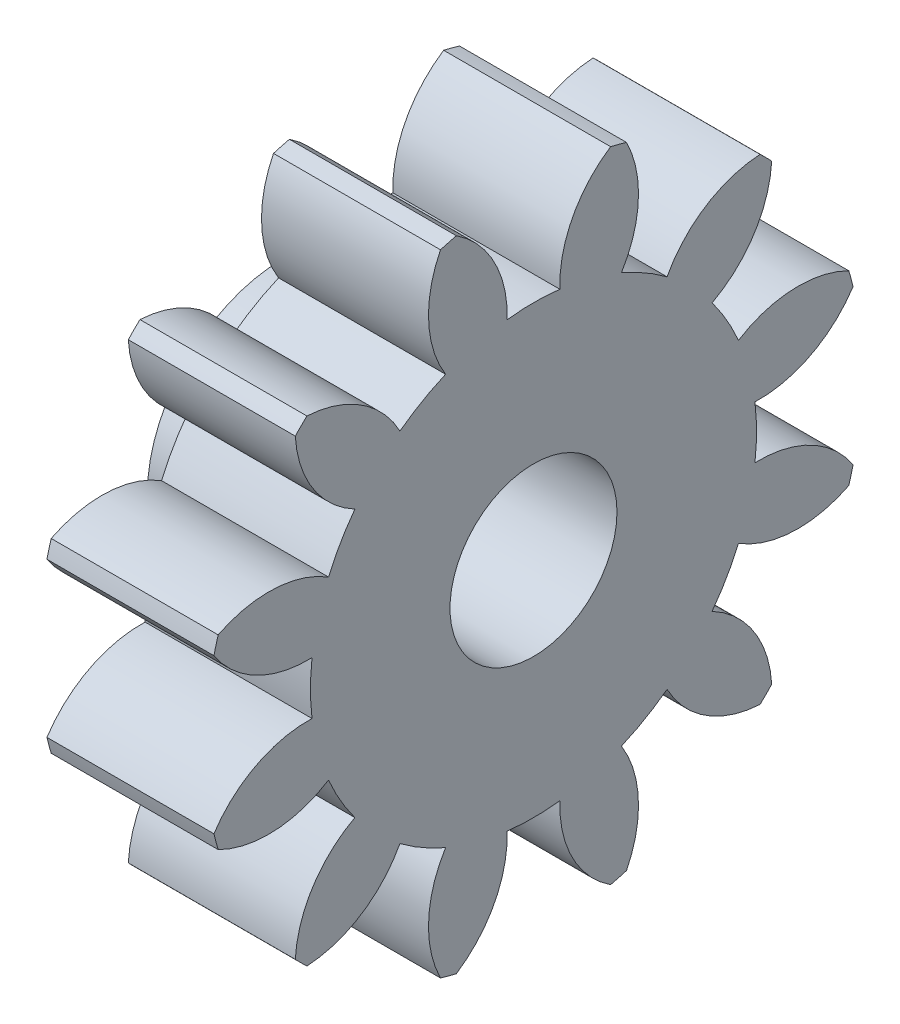
from build123d import *

# Parameters (mm, degrees)
BASPROSKE_W         = 4
BASPROSKE_H         = 7.875
TOOTHCUT_DEPTH      = 12.833480046
TEETHCUTS_COUNT     = 12
TEETHCUTS_ANGLE     = 330
BORSKE_R            = 1
BORE_DEPTH          = 50.0000508
SKETCH1_R           = 3.25
SKETCH1_R_2         = 2.25
BOSS_EXTRUDE1_DEPTH = 2
SKETCH2_R           = 2
CUT_EXTRUDE1_DEPTH  = 3


with BuildPart() as part:
    # BasProSke → Base-Revolve (revolve)
    with BuildSketch(Plane(origin=(0, 0, 0), x_dir=(1, 0, 0), z_dir=(0, 1, 0)), mode=Mode.PRIVATE) as base_revolve_sk:
        with Locations((2, 3.9375)):
            Rectangle(BASPROSKE_W, BASPROSKE_H)
    revolve(base_revolve_sk.sketch.rotate(Axis((-10, 0, 0), (1, 0, 0)), 180), axis=Axis((-10, 0, 0), (1, 0, 0)))

    # TooCutSke → ToothCut (cut, through all)
    with BuildSketch(Plane(origin=(0, 0, 0), x_dir=(0, 0, -1), z_dir=(1, 0, 0))):
        with BuildLine():
            ThreePointArc((0.631439839, 5.305305014), (0, 5.34275), (-0.631439839, 5.305305014))
            ThreePointArc((-0.631439839, 5.305305014), (-0.93992237, 6.654932089), (-1.876748184, 7.674251521))
            ThreePointArc((-1.876748184, 7.674251521), (0, 7.9004), (1.876748184, 7.674251521))
            ThreePointArc((1.876748184, 7.674251521), (0.93992237, 6.654932089), (0.631439839, 5.305305014))
        make_face()
    toothcut = extrude(amount=TOOTHCUT_DEPTH, mode=Mode.SUBTRACT)

    # TeethCuts: ToothCut ×12 about axis
    teethcuts_axis = Axis((-10, 0, 0), (1, 0, 0))
    for i in range(1, TEETHCUTS_COUNT):
        add(toothcut.rotate(teethcuts_axis, i * TEETHCUTS_ANGLE / (TEETHCUTS_COUNT - 1)), mode=Mode.SUBTRACT)

    # BorSke → Bore (cut, symmetric)
    with BuildSketch(Plane(origin=(0, 0, 0), x_dir=(0, 0, -1), z_dir=(1, 0, 0))):
        with Locations(Location((0, 0, 0), (0, 0, 180))):
            Circle(BORSKE_R)
    extrude(amount=BORE_DEPTH, both=True, mode=Mode.SUBTRACT)

    # Sketch1 → Boss-Extrude1 (add)
    with BuildSketch(Plane.ZY):
        with Locations(Location((0, 0, 0), (0, 0, 180))):
            Circle(SKETCH1_R)
        Circle(SKETCH1_R_2, mode=Mode.SUBTRACT)
    extrude(amount=BOSS_EXTRUDE1_DEPTH)

    # Sketch2 → Cut-Extrude1 (cut)
    with BuildSketch(Plane(origin=(4, 0, 0), x_dir=(0, 0, -1), z_dir=(1, 0, 0))):
        Circle(SKETCH2_R)
    extrude(amount=-CUT_EXTRUDE1_DEPTH, mode=Mode.SUBTRACT)


solid = part.part
